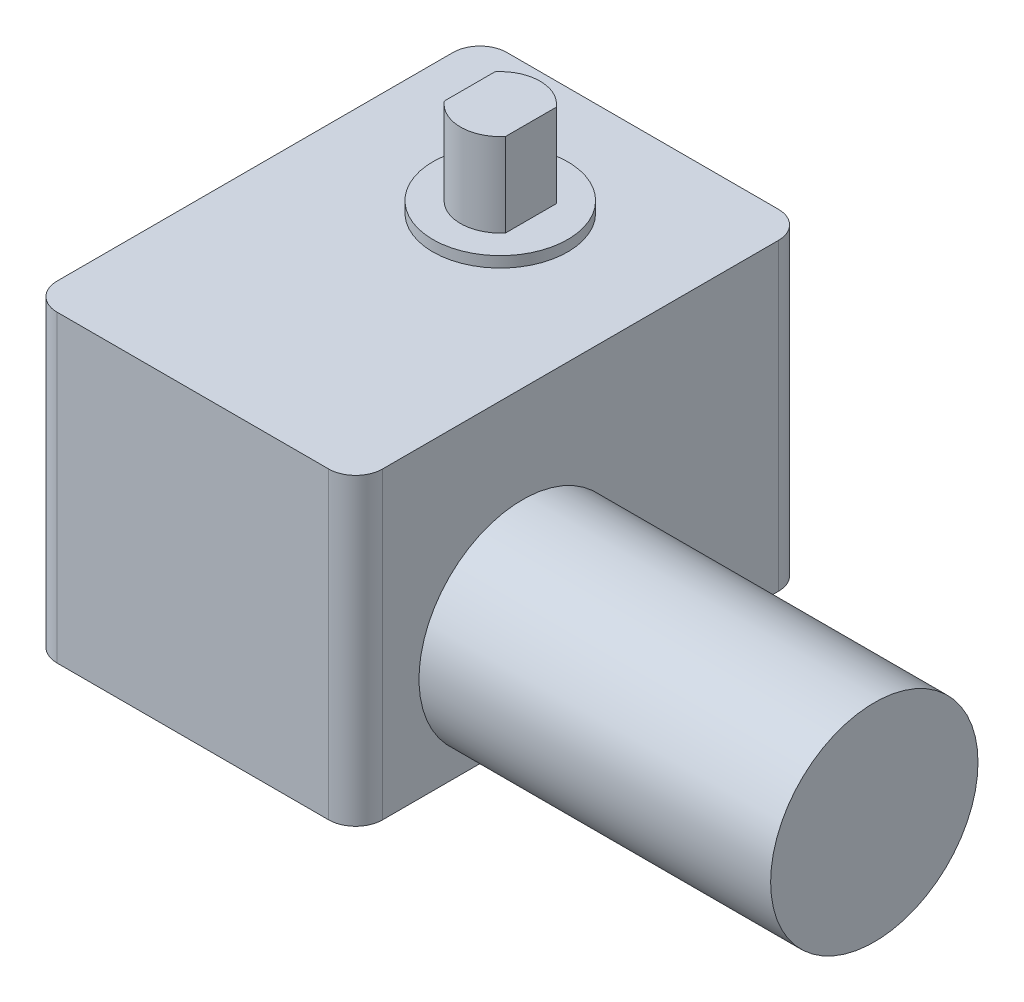
from build123d import *

# Parameters (mm, degrees)
SKETCH2_W           = 13.04
SKETCH2_H           = 3.845
SKETCH2_5_W         = 12.07
SKETCH2_5_H         = 16.68
BOSS_EXTRUDE1_DEPTH = 3.845
SKETCH2_6_R         = 2.5
BOSS_EXTRUDE2_DEPTH = 7.425
SKETCH2_7_R         = 2.5
BOSS_EXTRUDE3_DEPTH = 7.825
BOSS_EXTRUDE4_DEPTH = 10.925
FILLET1_R           = 1


with BuildPart() as part:
    # Sketch2 → Revolve1 (revolve)
    with BuildSketch(Plane(origin=(0, 0, 0), x_dir=(1, 0, 0), z_dir=(0, 1, 0))):
        with Locations((18.59, 4.2725)):
            Rectangle(SKETCH2_W, SKETCH2_H)
    revolve(axis=Axis((25.11, 0, -6.195), (-1, 0, 0)))

    # Sketch2_5 → Boss-Extrude1 (add)
    with BuildSketch(Plane(origin=(0, 0, 0), x_dir=(1, 0, 0), z_dir=(0, 1, 0))):
        with Locations((6.035, 8.34)):
            Rectangle(SKETCH2_5_W, SKETCH2_5_H)
    extrude(amount=-BOSS_EXTRUDE1_DEPTH)

    # Sketch2_6 → Boss-Extrude2 (add)
    with BuildSketch(Plane(origin=(0, 0, 0), x_dir=(1, 0, 0), z_dir=(0, 1, 0))):
        Polygon((0, 16.68), (0, 0), (12.07, 0), (12.07, 2.35), (12.07, 6.195), (12.07, 10.04), (12.07, 16.68), align=None)
        with Locations((6.035, 11.4)):
            Circle(SKETCH2_6_R, mode=Mode.SUBTRACT)
    extrude(amount=BOSS_EXTRUDE2_DEPTH)

    # Sketch2_7 → Boss-Extrude3 (add)
    with BuildSketch(Plane(origin=(0, 0, 0), x_dir=(1, 0, 0), z_dir=(0, 1, 0))):
        with Locations((6.035, 11.4)):
            Circle(SKETCH2_7_R)
        with BuildLine():
            ThreePointArc((7.171672776, 12.34), (6.035, 12.875), (4.898327224, 12.34))
            Line((4.898327224, 12.34), (4.898327224, 10.46))
            ThreePointArc((4.898327224, 10.46), (6.035, 9.925), (7.171672776, 10.46))
            Line((7.171672776, 10.46), (7.171672776, 12.34))
        make_face(mode=Mode.SUBTRACT)
    extrude(amount=BOSS_EXTRUDE3_DEPTH)

    # Sketch2_8 → Boss-Extrude4 (add)
    with BuildSketch(Plane(origin=(0, 0, 0), x_dir=(1, 0, 0), z_dir=(0, 1, 0))):
        with BuildLine():
            Line((7.171672776, 12.34), (7.171672776, 10.46))
            ThreePointArc((7.171672776, 10.46), (6.035, 9.925), (4.898327224, 10.46))
            Line((4.898327224, 10.46), (4.898327224, 12.34))
            ThreePointArc((4.898327224, 12.34), (6.035, 12.875), (7.171672776, 12.34))
        make_face()
    extrude(amount=BOSS_EXTRUDE4_DEPTH)

    # Fillet1
    fillet1_edges = [part.edges().sort_by_distance(p)[0] for p in [
        (12.07, 1.79, -16.68),
        (12.07, 1.79, 0),
        (0, 1.79, 0),
        (0, 1.79, -16.68),
    ]]
    fillet(fillet1_edges, radius=FILLET1_R)


solid = part.part
